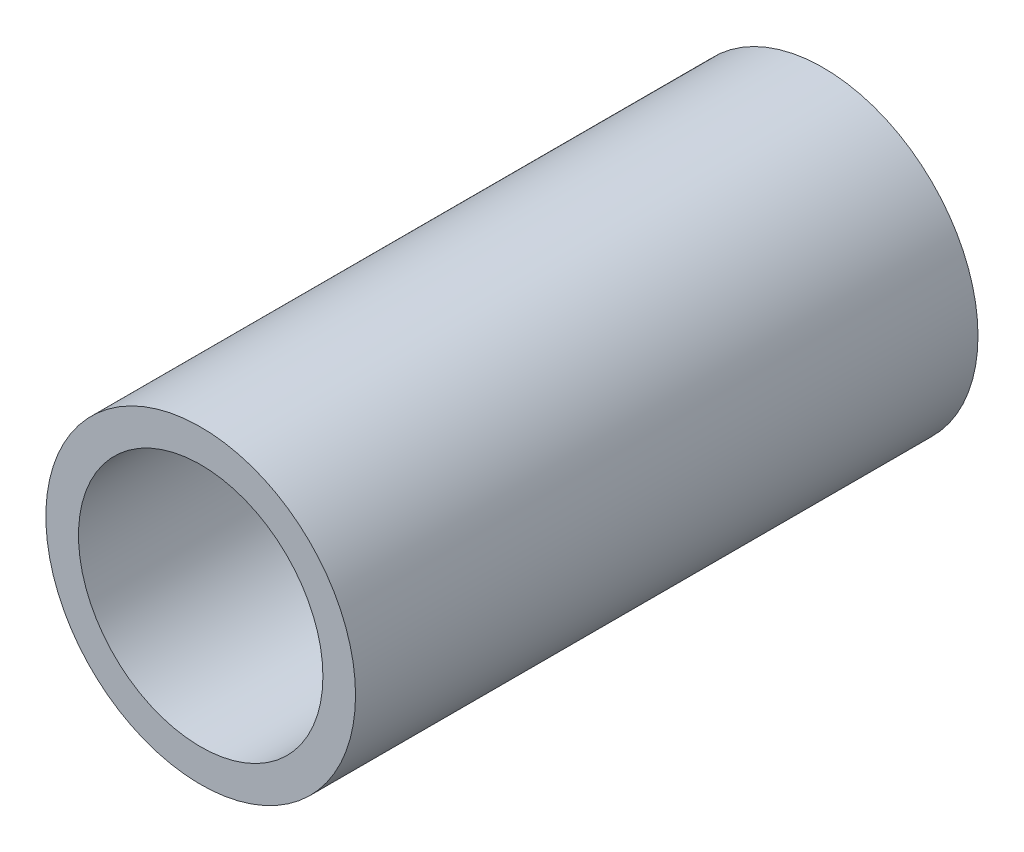
from build123d import *

# Parameters (mm, degrees)
SKETCH1_R                = 12.7
SKETCH1_R_2              = 10.025
BOSS_EXTRUDE1_DEPTH      = 50.8
BOSS_EXTRUDE1_DEPTH_BACK = 0.254


with BuildPart() as part:
    # Sketch1 → Boss-Extrude1 (new body, two sides)
    with BuildSketch(Plane(origin=(0, 0, 0), x_dir=(0, 1, 0), z_dir=(0, 0, 1))) as boss_extrude1_sk:
        Circle(SKETCH1_R)
        Circle(SKETCH1_R_2, mode=Mode.SUBTRACT)
    extrude(amount=BOSS_EXTRUDE1_DEPTH)
    extrude(boss_extrude1_sk.sketch, amount=-BOSS_EXTRUDE1_DEPTH_BACK)


solid = part.part
